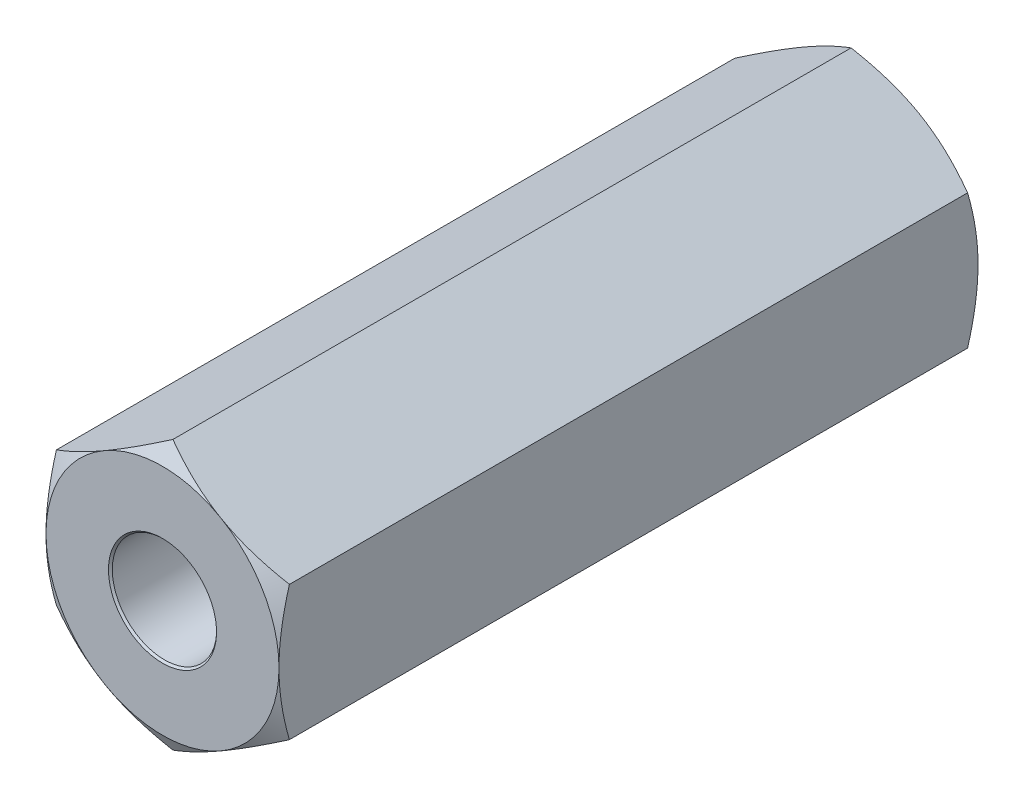
from build123d import *

# Parameters (mm, degrees)
EXTRUDE1_DEPTH          = 9.525
EXTRUDE1_DEPTH_BACK     = 9.525
SKETCH1_R               = 1.4224
SKETCH8_OUTSIDE_W       = 84.186
SKETCH8_OUTSIDE_H       = 85.168
SKETCH8_OUTSIDE_R       = 3.175
EXTRUDE4_DEPTH          = 20.657669199
EXTRUDE4_DRAFT          = -60
MIRROR1_COPY_1_SKETCH_W = 84.186
MIRROR1_COPY_1_SKETCH_H = 85.168
MIRROR1_COPY_1_SKETCH_R = 3.175
MIRROR1_COPY_1_DEPTH    = 20.657669199
MIRROR1_COPY_1_DRAFT    = -60


with BuildPart() as part:
    # Sketch1 → Extrude1 (new, two sides: drawn at the far end of the back side and taken through both)
    with BuildSketch(Plane.XY.offset(-EXTRUDE1_DEPTH_BACK)):
        Polygon((0, 3.666174209), (-3.175, 1.833087105), (-3.175, -1.833087105), (0, -3.666174209), (3.175, -1.833087105), (3.175, 1.833087105), align=None)
        with Locations(Location((0, 0, 0), (0, 0, 180))):
            Circle(SKETCH1_R, mode=Mode.SUBTRACT)
    extrude(amount=EXTRUDE1_DEPTH + EXTRUDE1_DEPTH_BACK)

    # Extrude3 cone 1 section (through the dimple's axis) → Extrude3 (revolve, cut)
    with BuildSketch(Plane(origin=(0, 0, -9.525), x_dir=(0, 1, 0), z_dir=(1, 0, 0))):
        Polygon((0, 0), (1.4732, 0), (0, 1.579813584), align=None)
    extrude3 = revolve(axis=Axis((0, 0, -9.525), (0, 0, 1)), mode=Mode.SUBTRACT)


with BuildPart() as extrude4_tool:
    # Sketch8 outside → Extrude4 (with draft: the straight prism first)
    with BuildSketch(Plane(origin=(0, 0, -9.525), x_dir=(-1, 0, 0), z_dir=(0, 0, -1))):
        Rectangle(SKETCH8_OUTSIDE_W, SKETCH8_OUTSIDE_H)
        Circle(SKETCH8_OUTSIDE_R, mode=Mode.SUBTRACT)
    extrude(amount=-EXTRUDE4_DEPTH)
    # Extrude4: the draft: its side faces are tilted about the plane it starts from
    extrude4_sides = [extrude4_tool.faces().sort_by_distance(p)[0] for p in [
        (0, -42.584, 0.803834599),
        (-42.093, 0, 0.803834599),
        (0, 42.584, 0.803834599),
        (42.093, 0, 0.803834599),
        (3.175, 0, 0.803834599),
    ]]
    draft(extrude4_sides, Plane(origin=(0, 0, -9.525), x_dir=(-1, 0, 0), z_dir=(0, 0, -1)), EXTRUDE4_DRAFT)


with BuildPart() as part_1:
    add(part.part)

    # Extrude4: cut by extrude4_tool
    add(extrude4_tool.part, mode=Mode.SUBTRACT)

    # Mirror1: Extrude3 across plane
    add(extrude3.mirror(Plane.XY), mode=Mode.SUBTRACT)


with BuildPart() as mirror1_copy_1_tool:
    # Mirror1 copy 1 sketch → Mirror1 copy 1 (with draft: the straight prism first)
    with BuildSketch(Plane(origin=(0, 0, 9.525), x_dir=(-1, 0, 0), z_dir=(0, 0, 1))):
        Rectangle(MIRROR1_COPY_1_SKETCH_W, MIRROR1_COPY_1_SKETCH_H)
        Circle(MIRROR1_COPY_1_SKETCH_R, mode=Mode.SUBTRACT)
    extrude(amount=-MIRROR1_COPY_1_DEPTH)
    # Mirror1 copy 1: the draft: its side faces are tilted about the plane it starts from
    mirror1_copy_1_sides = [mirror1_copy_1_tool.faces().sort_by_distance(p)[0] for p in [
        (0, -42.584, -0.803834599),
        (-42.093, 0, -0.803834599),
        (0, 42.584, -0.803834599),
        (42.093, 0, -0.803834599),
        (3.175, 0, -0.803834599),
    ]]
    draft(mirror1_copy_1_sides, Plane(origin=(0, 0, 9.525), x_dir=(-1, 0, 0), z_dir=(0, 0, 1)), MIRROR1_COPY_1_DRAFT)


with BuildPart() as part_2:
    add(part_1.part)

    # Mirror1 copy 1: cut by mirror1_copy_1_tool
    add(mirror1_copy_1_tool.part, mode=Mode.SUBTRACT)


solid = part_2.part
